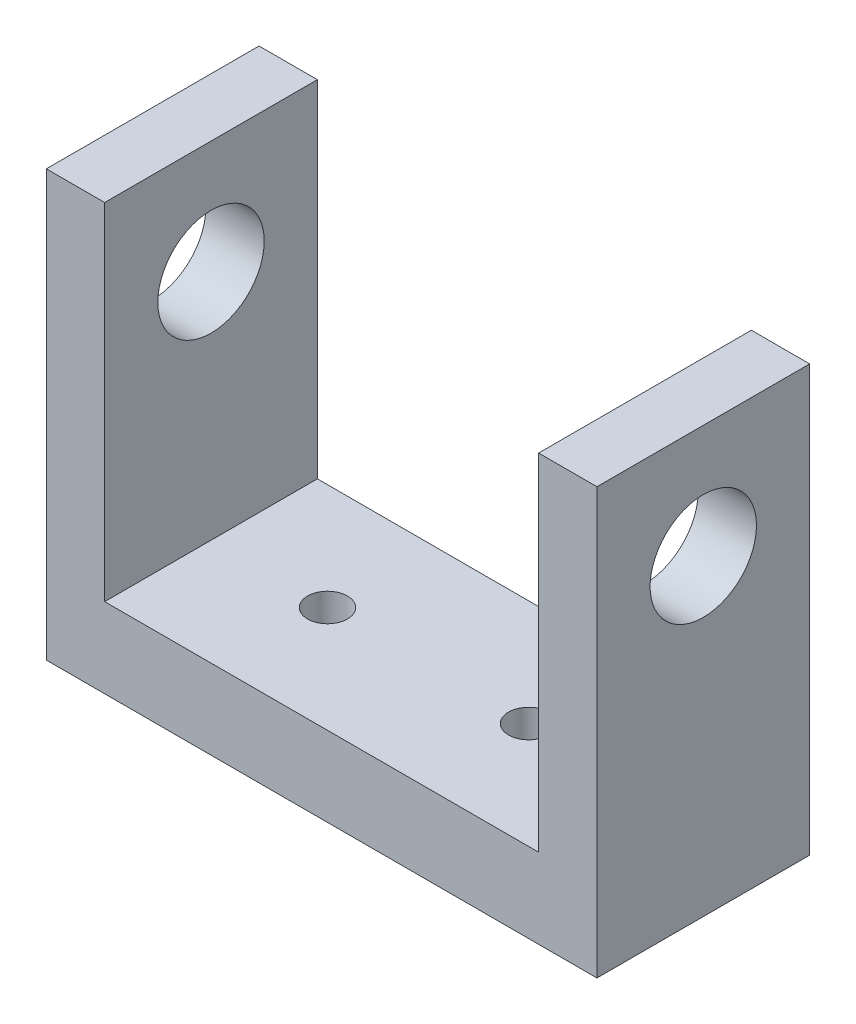
from build123d import *

# Parameters (mm, degrees)
SKETCH1_W             = 16.435294118
SKETCH1_H             = 6.35
BOSS_EXTRUDE1_DEPTH   = 12.7
SKETCH2_W             = 12.954
SKETCH2_H             = 6.35
CUT_EXTRUDE1_DEPTH    = 10.31875
SKETCH3_R             = 1.5875
CUT_EXTRUDE2_DEPTH    = 17.435294118
F_0_80_TAPPED_HOLE1_D = 1.19126


with BuildPart() as part:
    # Sketch1 → Boss-Extrude1 (new body)
    with BuildSketch(Plane(origin=(0, 0, 0), x_dir=(1, 0, 0), z_dir=(0, 1, 0))):
        Rectangle(SKETCH1_W, SKETCH1_H)
    extrude(amount=BOSS_EXTRUDE1_DEPTH)

    # Sketch2 → Cut-Extrude1 (cut)
    with BuildSketch(Plane(origin=(0, 12.7, 0), x_dir=(-1, 0, 0), z_dir=(0, 1, 0))):
        Rectangle(SKETCH2_W, SKETCH2_H)
    extrude(amount=-CUT_EXTRUDE1_DEPTH, mode=Mode.SUBTRACT)

    # Sketch3 → Cut-Extrude2 (cut, through all)
    with BuildSketch(Plane(origin=(8.217647059, 0, 0), x_dir=(0, 0, -1), z_dir=(1, 0, 0))):
        with Locations((0, 9.3218)):
            Circle(SKETCH3_R)
    extrude(amount=-CUT_EXTRUDE2_DEPTH, mode=Mode.SUBTRACT)

    # #0-80 Tapped Hole1 (through all)
    with Locations(Plane(origin=(0, 2.38125, 0), x_dir=(-1, 0, 0), z_dir=(0, 1, 0))):
        with Locations((3, 0), (-3, 0)):
            Hole(F_0_80_TAPPED_HOLE1_D / 2)


solid = part.part
